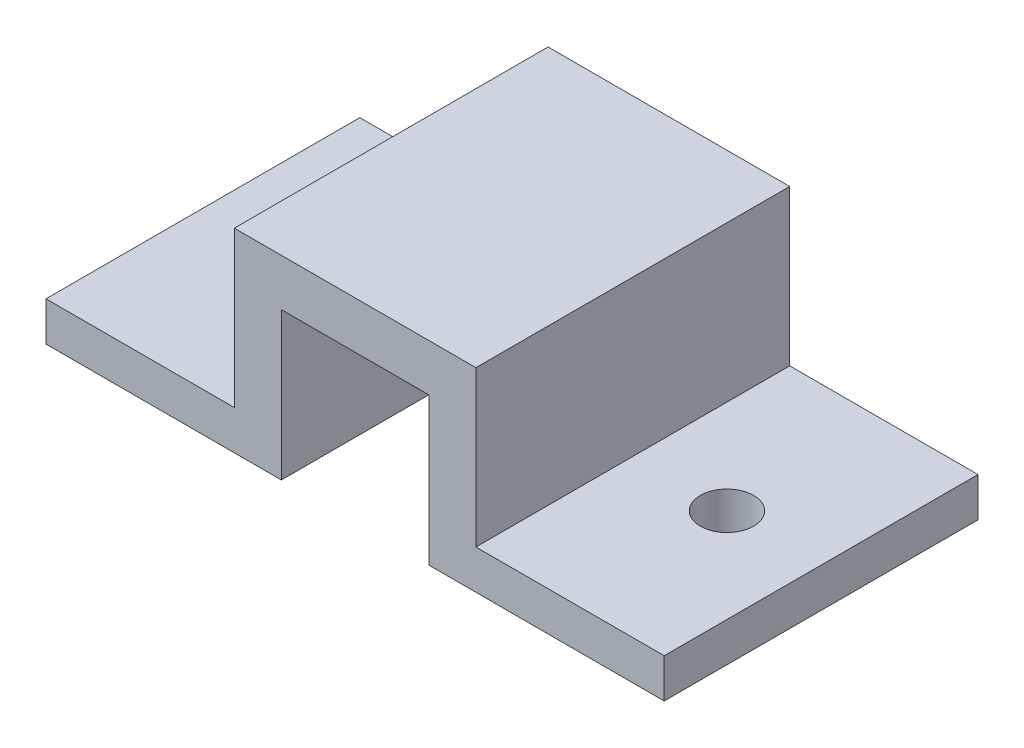
from build123d import *

# Parameters (mm, degrees)
BOSS_EXTRUDE1_DEPTH = 25.4
SKETCH2_R           = 2.159
CUT_EXTRUDE1_DEPTH  = 25.4
SKETCH3_R           = 2.159
CUT_EXTRUDE2_DEPTH  = 25.4


with BuildPart() as part:
    # Sketch1 → Boss-Extrude1 (new body)
    with BuildSketch(Plane.XY):
        Polygon((-9.009241013, -10.149737798), (-28.059241013, -10.149737798), (-28.059241013, -6.974737798), (-12.819241013, -6.974737798), (-12.819241013, 5.598262202), (6.738758987, 5.598262202), (6.738758987, -6.974737798), (21.978758987, -6.974737798), (21.978758987, -10.149737798), (2.928758987, -10.149737798), (2.928758987, 1.788262202), (-9.009241013, 1.788262202), align=None)
    extrude(amount=BOSS_EXTRUDE1_DEPTH)

    # Sketch2 → Cut-Extrude1 (cut)
    with BuildSketch(Plane(origin=(0, -6.974737798, 0), x_dir=(1, 0, 0), z_dir=(0, 1, 0))):
        with Locations((14.358758987, -12.7)):
            Circle(SKETCH2_R)
    extrude(amount=-CUT_EXTRUDE1_DEPTH, mode=Mode.SUBTRACT)

    # Sketch3 → Cut-Extrude2 (cut)
    with BuildSketch(Plane(origin=(0, -6.974737798, 0), x_dir=(1, 0, 0), z_dir=(0, 1, 0))):
        with Locations((-20.439241013, -12.7)):
            Circle(SKETCH3_R)
    extrude(amount=-CUT_EXTRUDE2_DEPTH, mode=Mode.SUBTRACT)


solid = part.part
